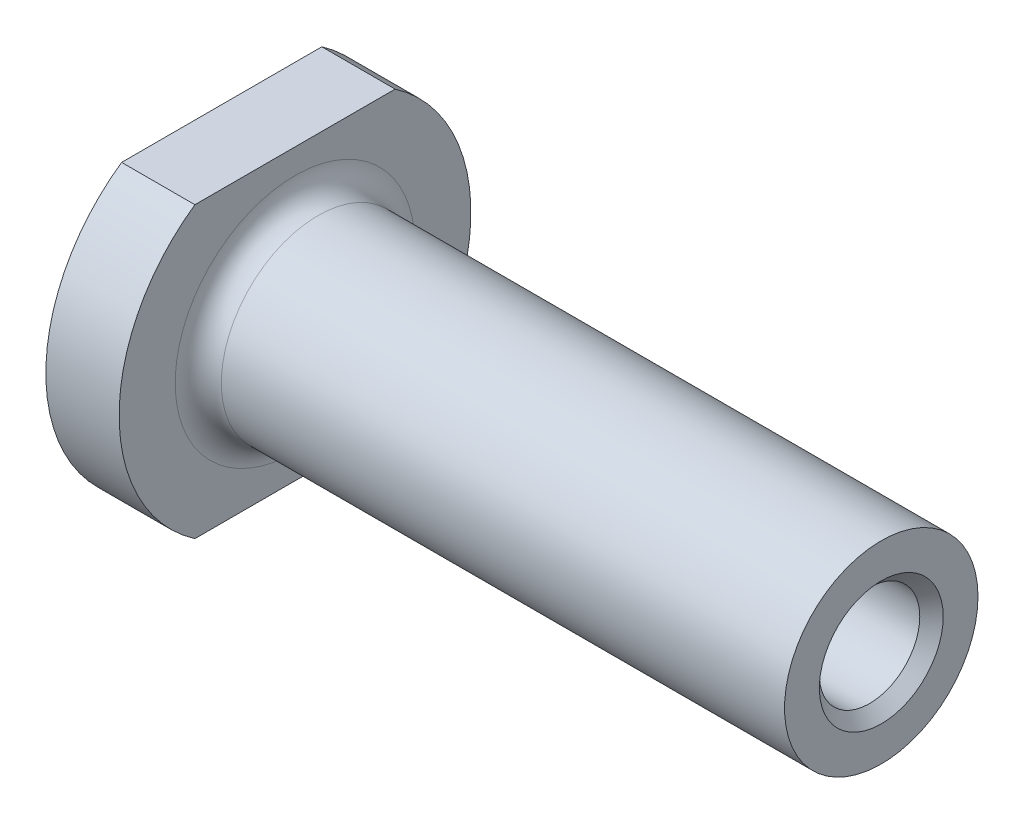
from build123d import *

# Parameters (mm, degrees)
FILLET1_R             = 1.5
HOLE_WIZARD_5_16_18_D = 6.5278
CUT_EXTRUDE1_DEPTH    = 43.8625
CHAMFER1_SIZE         = 0.762


with BuildPart() as part:
    # Sketch1 → Revolve1 (revolve)
    with BuildSketch(Plane.XY):
        Polygon((0, 0), (42.8625, 0), (42.8625, 6.2865), (4.7625, 6.2865), (4.7625, 11.43), (0, 11.43), align=None)
    revolve(axis=Axis((0, 0, 0), (-1, 0, 0)))

    # Fillet1
    fillet1_edges = [part.edges().sort_by_distance(p)[0] for p in [
        (4.7625, -6.2865, 0),
    ]]
    fillet(fillet1_edges, radius=FILLET1_R)

    # 5/16-18 (through all)
    with Locations(Plane(origin=(42.8625, 0, 0), x_dir=(0, 0, -1), z_dir=(1, 0, 0))):
        with Locations((0, 0)):
            Hole(HOLE_WIZARD_5_16_18_D / 2)

    # Sketch4 → Cut-Extrude1 (cut, through all)
    with BuildSketch(Plane.ZY):
        with BuildLine():
            Line((-6.505574225, 9.398), (6.505574225, 9.398))
            ThreePointArc((6.505574225, 9.398), (0, 11.43), (-6.505574225, 9.398))
        make_face()
        with BuildLine():
            Line((6.505574225, -9.398), (-6.505574225, -9.398))
            ThreePointArc((-6.505574225, -9.398), (0, -11.43), (6.505574225, -9.398))
        make_face()
    extrude(amount=-CUT_EXTRUDE1_DEPTH, mode=Mode.SUBTRACT)

    # Chamfer1
    chamfer1_edges = [part.edges().sort_by_distance(p)[0] for p in [
        (42.8625, 0, -3.2639),
        (0, 0, -3.2639),
    ]]
    chamfer(chamfer1_edges, length=CHAMFER1_SIZE)


solid = part.part
